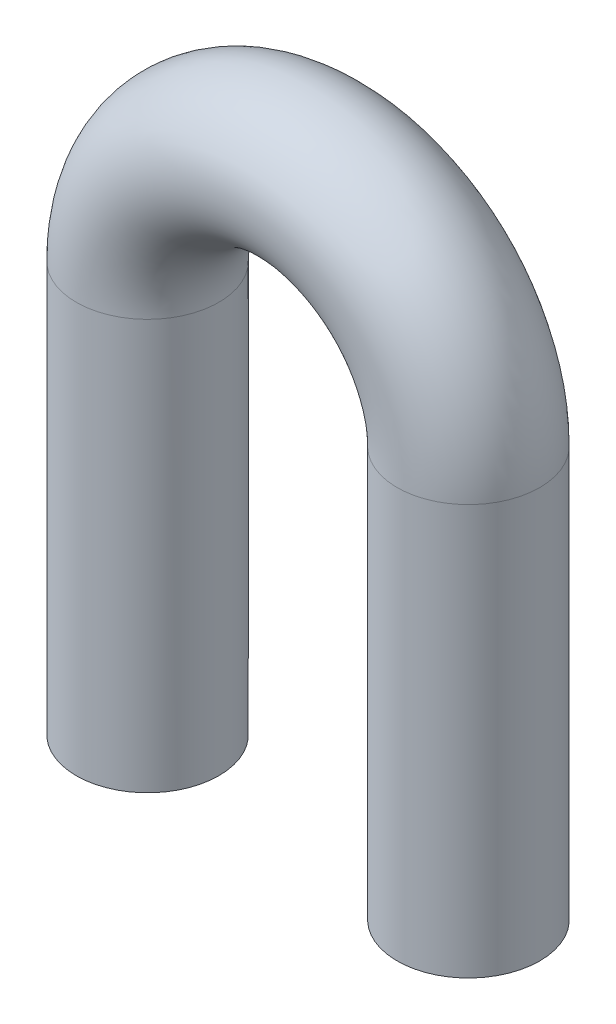
from build123d import *

# Parameters (mm, degrees)
SKETCH1_R           = 2
REVOLVE1_ANGLE      = 180
SKETCH2_R           = 2
BOSS_EXTRUDE1_DEPTH = 11.5


with BuildPart() as part:
    # Sketch1 → Revolve1 (revolve)
    with BuildSketch(Plane(origin=(0, 0, 0), x_dir=(1, 0, 0), z_dir=(0, 1, 0))):
        with Locations((4.5, 0)):
            Circle(SKETCH1_R)
    revolve(axis=Axis((0, 0, 188.267496387), (0, 0, 1)), revolution_arc=REVOLVE1_ANGLE)

    # Sketch2 → Boss-Extrude1 (add)
    with BuildSketch(Plane.XZ):
        with Locations((4.5, 0)):
            Circle(SKETCH2_R)
        with Locations((-4.5, 0)):
            Circle(SKETCH2_R)
    extrude(amount=BOSS_EXTRUDE1_DEPTH)


solid = part.part
